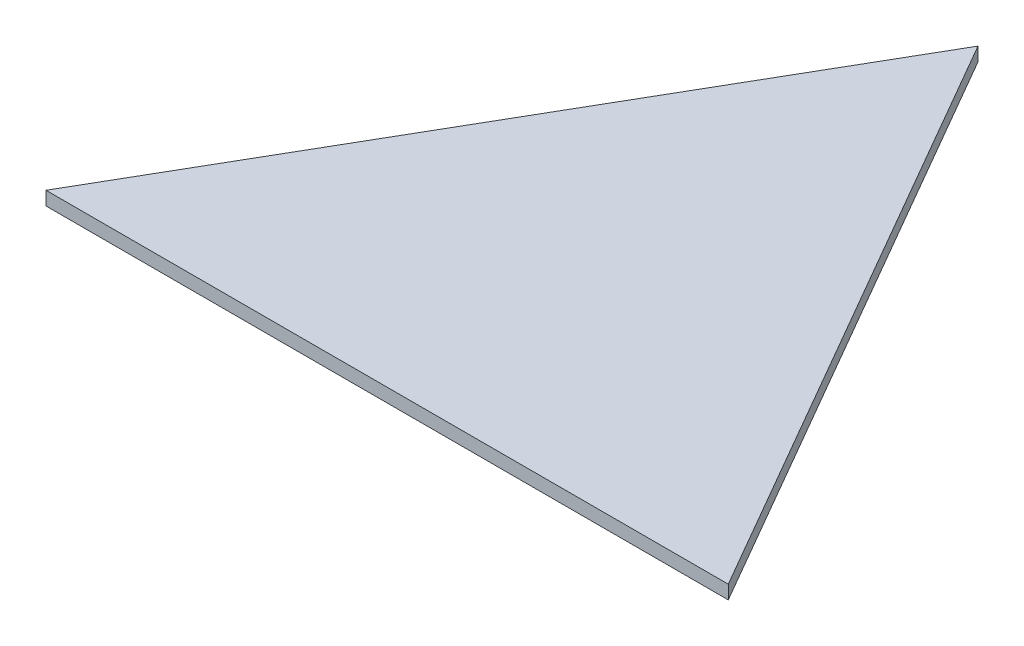
from build123d import *

# Parameters (mm, degrees)
BOSS_EXTRUDE1_DEPTH = 3


with BuildPart() as part:
    # Sketch2 → Boss-Extrude1 (new body)
    with BuildSketch(Plane(origin=(0, 0, 0), x_dir=(1, 0, 0), z_dir=(0, 1, 0))):
        Polygon((-75, -54.903810568), (75, -54.903810568), (0, 75), align=None)
    extrude(amount=BOSS_EXTRUDE1_DEPTH)


solid = part.part
